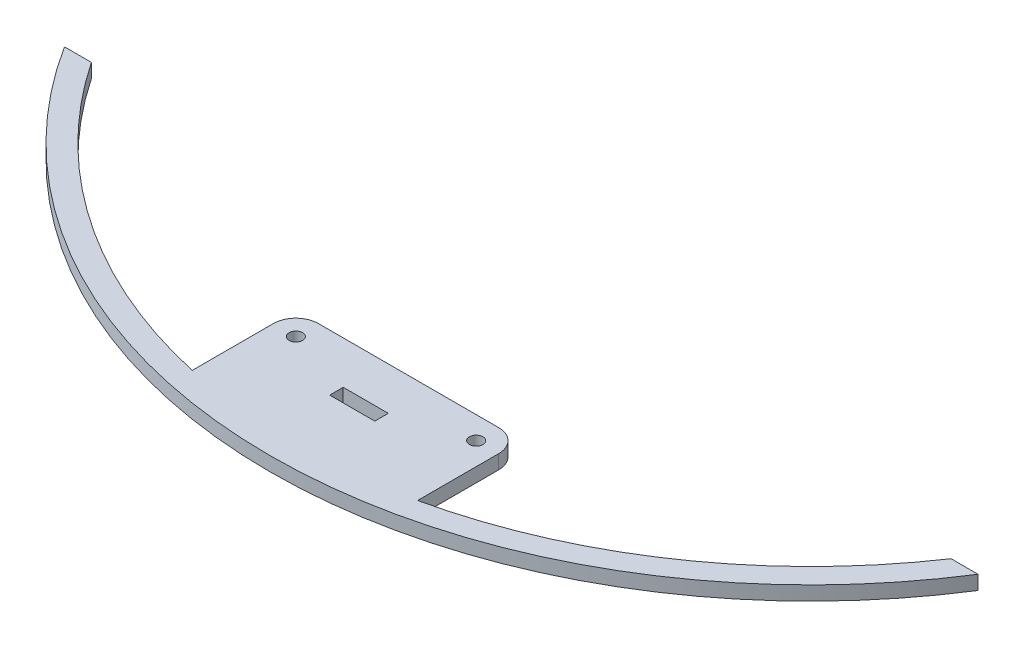
from build123d import *

# Parameters (mm, degrees)
SKETCH_1_R      = 1.5
SKETCH_1_W      = 10
SKETCH_1_H      = 3
EXTRUDE_2_DEPTH = 3.125


with BuildPart() as part:
    # 草图1 → 凸台-拉伸2 (new body)
    with BuildSketch(Plane(origin=(0, 0, 0), x_dir=(1, 0, 0), z_dir=(0, 1, 0))):
        with BuildLine():
            Line((-101.350743825, 30), (-95.378054467, 30))
            ThreePointArc((-95.378054467, 30), (-64.797523096, -0.757020266), (-25, -18))
            Line((-25, -18), (-25, 0))
            ThreePointArc((-25, 0), (-23.535533906, 3.535533906), (-20, 5))
            Line((-20, 5), (20, 5))
            ThreePointArc((20, 5), (23.535533906, 3.535533906), (25, 0))
            Line((25, 0), (25, -18))
            ThreePointArc((25, -18), (64.797523096, -0.757020266), (95.378054467, 30))
            Line((95.378054467, 30), (101.350743825, 30))
            ThreePointArc((101.350743825, 30), (0, -25.750278397), (-101.350743825, 30))
        make_face()
        with Locations((-20, 0)):
            Circle(SKETCH_1_R, mode=Mode.SUBTRACT)
        with Locations((20, 0)):
            Circle(SKETCH_1_R, mode=Mode.SUBTRACT)
        with Locations((0, -6)):
            Rectangle(SKETCH_1_W, SKETCH_1_H, mode=Mode.SUBTRACT)
    extrude(amount=EXTRUDE_2_DEPTH)


solid = part.part
